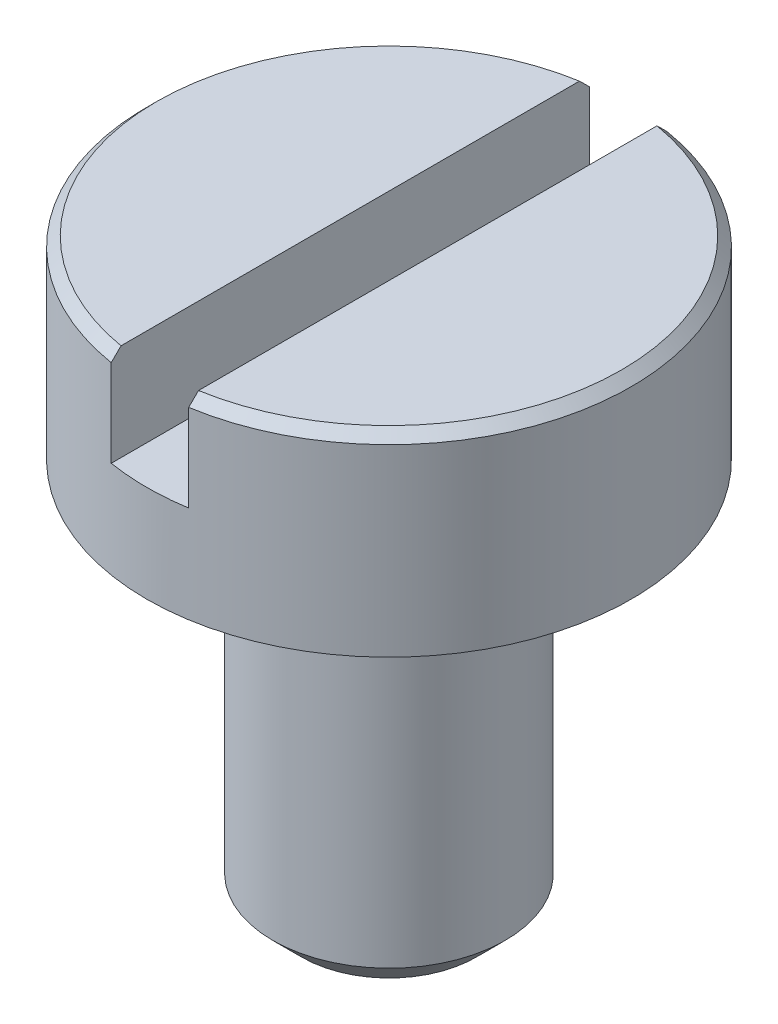
from build123d import *

# Parameters (mm, degrees)
SKETCH1_R               = 1.25
BOSS_EXTRUDE1_DEPTH     = 1
SKETCH2_R               = 0.6
BOSS_EXTRUDE2_DEPTH     = 2
CHAMFER1_SIZE           = 0.05
CHAMFER2_SIZE           = 0.15
CUT_EXTRUDE1_DEPTH      = 2.25
CUT_EXTRUDE1_DEPTH_BACK = 2.25


with BuildPart() as part:
    # Sketch1 → Boss-Extrude1 (new body)
    with BuildSketch(Plane(origin=(0, 0, 0), x_dir=(1, 0, 0), z_dir=(0, 1, 0))):
        Circle(SKETCH1_R)
    extrude(amount=BOSS_EXTRUDE1_DEPTH)

    # Sketch2 → Boss-Extrude2 (add)
    with BuildSketch(Plane(origin=(0, 0, 0), x_dir=(1, 0, 0), z_dir=(0, 1, 0))):
        Circle(SKETCH2_R)
    extrude(amount=-BOSS_EXTRUDE2_DEPTH)

    # Chamfer1
    chamfer1_edges = [part.edges().sort_by_distance(p)[0] for p in [
        (-1.25, 1, 0),
    ]]
    chamfer(chamfer1_edges, length=CHAMFER1_SIZE)

    # Chamfer2
    chamfer2_edges = [part.edges().sort_by_distance(p)[0] for p in [
        (-0.6, -2, 0),
    ]]
    chamfer(chamfer2_edges, length=CHAMFER2_SIZE)

    # Sketch3 → Cut-Extrude1 (cut, two sides)
    with BuildSketch(Plane.XY) as cut_extrude1_sk:
        Polygon((-0.2, 1), (0, 1), (0.2, 1), (0.2, 0.5), (0, 0.5), (-0.2, 0.5), align=None)
    extrude(amount=CUT_EXTRUDE1_DEPTH, mode=Mode.SUBTRACT)
    extrude(cut_extrude1_sk.sketch, amount=-CUT_EXTRUDE1_DEPTH_BACK, mode=Mode.SUBTRACT)


solid = part.part
